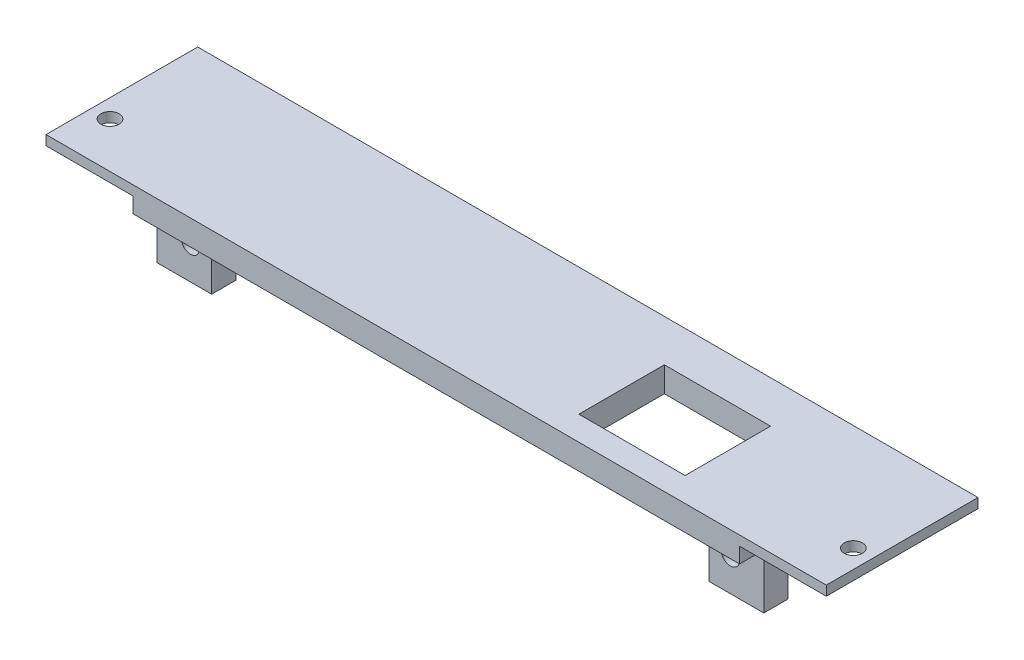
from build123d import *

# Parameters (mm, degrees)
SKETCH1_W           = 128.6
SKETCH1_H           = 25
SKETCH1_R           = 1.5
SKETCH1_W_2         = 17.508
SKETCH1_H_2         = 14.090792215
BOSS_EXTRUDE1_DEPTH = 1.6
SKETCH3_W           = 100
SKETCH3_H           = 25
SKETCH3_W_2         = 17.508
SKETCH3_H_2         = 14.090792215
BOSS_EXTRUDE4_DEPTH = 2.54
SKETCH4_W           = 9
SKETCH4_H           = 9
SKETCH4_R           = 1.5
BOSS_EXTRUDE5_DEPTH = 4
FILLET1_R           = 2


with BuildPart() as part:
    # Sketch1 → Boss-Extrude1 (new body)
    with BuildSketch(Plane(origin=(0, 0, 0), x_dir=(1, 0, 0), z_dir=(0, 1, 0))):
        Rectangle(SKETCH1_W, SKETCH1_H)
        with Locations((-61.25, -5)):
            Circle(SKETCH1_R, mode=Mode.SUBTRACT)
        with Locations((61.25, -5)):
            Circle(SKETCH1_R, mode=Mode.SUBTRACT)
        with Locations((28.271706015, -1.454603892)):
            Rectangle(SKETCH1_W_2, SKETCH1_H_2, mode=Mode.SUBTRACT)
    extrude(amount=BOSS_EXTRUDE1_DEPTH)

    # Sketch3 → Boss-Extrude4 (add)
    with BuildSketch(Plane(origin=(0, 0, 0), x_dir=(1, 0, 0), z_dir=(0, 1, 0))):
        Rectangle(SKETCH3_W, SKETCH3_H)
        with Locations((28.271706015, -1.454603892)):
            Rectangle(SKETCH3_W_2, SKETCH3_H_2, mode=Mode.SUBTRACT)
    extrude(amount=-BOSS_EXTRUDE4_DEPTH)

    # Sketch4 → Boss-Extrude5 (add)
    with BuildSketch(Plane.XY.offset(8.5)):
        with Locations((-45.5, -7.04)):
            Rectangle(SKETCH4_W, SKETCH4_H)
        with Locations((-44.5, -6.08)):
            Circle(SKETCH4_R, mode=Mode.SUBTRACT)
        with Locations((45.5, -7.04)):
            Rectangle(SKETCH4_W, SKETCH4_H)
        with Locations((44.5, -6.08)):
            Circle(SKETCH4_R, mode=Mode.SUBTRACT)
    extrude(amount=-BOSS_EXTRUDE5_DEPTH)

    # Fillet1
    fillet1_edges = [part.edges().sort_by_distance(p)[0] for p in [
        (-45.5, -2.54, 4.5),
        (45.5, -2.54, 4.5),
    ]]
    fillet(fillet1_edges, radius=FILLET1_R)


solid = part.part
